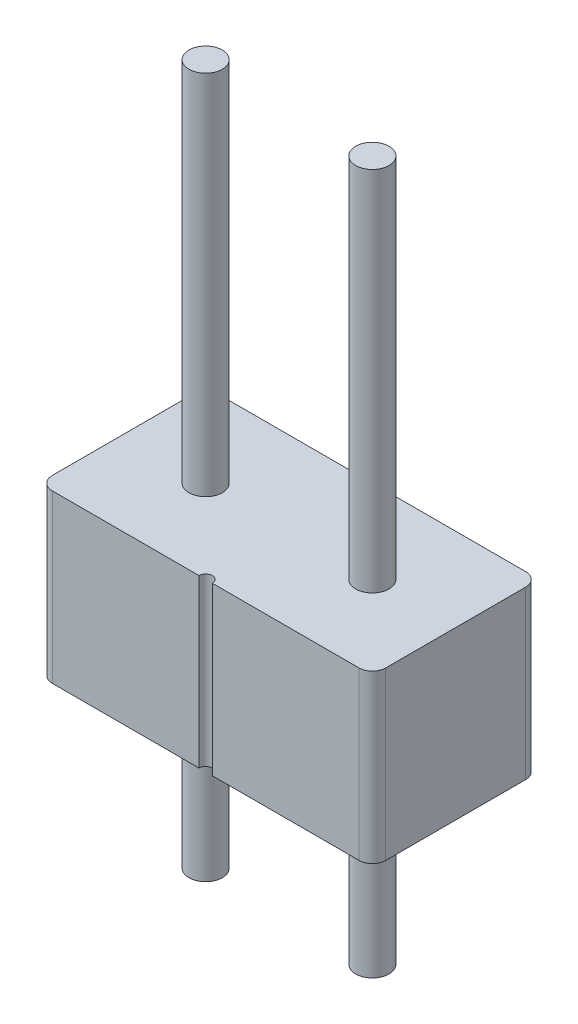
from build123d import *

# Parameters (mm, degrees)
IZIM1_R                          = 0.25
Y_KSEKLIK_EKSTR_ZYON1_DEPTH      = 2.5
IZIM2_R                          = 0.25
Y_KSEKLIK_EKSTR_ZYON2_DEPTH      = 5.5
Y_KSEKLIK_EKSTR_ZYON2_DEPTH_BACK = 5


with BuildPart() as part:
    # Çizim1 → Yükseklik-Ekstrüzyon1 (new body)
    with BuildSketch(Plane(origin=(0, 0, 0), x_dir=(1, 0, 0), z_dir=(0, 1, 0))):
        with BuildLine():
            Line((-2.3, 1.25), (-0.1, 1.25))
            ThreePointArc((-0.1, 1.25), (0, 1.15), (0.1, 1.25))
            Line((0.1, 1.25), (2.3, 1.25))
            ThreePointArc((2.3, 1.25), (2.441421356, 1.191421356), (2.5, 1.05))
            Line((2.5, 1.05), (2.5, -1.05))
            ThreePointArc((2.5, -1.05), (2.441421356, -1.191421356), (2.3, -1.25))
            Line((2.3, -1.25), (0.1, -1.25))
            ThreePointArc((0.1, -1.25), (0, -1.15), (-0.1, -1.25))
            Line((-0.1, -1.25), (-2.3, -1.25))
            ThreePointArc((-2.3, -1.25), (-2.441421356, -1.191421356), (-2.5, -1.05))
            Line((-2.5, -1.05), (-2.5, 1.05))
            ThreePointArc((-2.5, 1.05), (-2.441421356, 1.191421356), (-2.3, 1.25))
        make_face()
        with Locations((-1.25, 0)):
            Circle(IZIM1_R, mode=Mode.SUBTRACT)
        with Locations((1.25, 0)):
            Circle(IZIM1_R, mode=Mode.SUBTRACT)
    extrude(amount=Y_KSEKLIK_EKSTR_ZYON1_DEPTH)

    # Çizim2 → Yükseklik-Ekstrüzyon2 (add, two sides)
    with BuildSketch(Plane(origin=(0, 2.5, 0), x_dir=(1, 0, 0), z_dir=(0, 1, 0))) as y_kseklik_ekstr_zyon2_sk:
        with Locations((-1.25, 0)):
            Circle(IZIM2_R)
        with Locations((1.25, 0)):
            Circle(IZIM2_R)
    extrude(amount=Y_KSEKLIK_EKSTR_ZYON2_DEPTH)
    extrude(y_kseklik_ekstr_zyon2_sk.sketch, amount=-Y_KSEKLIK_EKSTR_ZYON2_DEPTH_BACK)


solid = part.part
